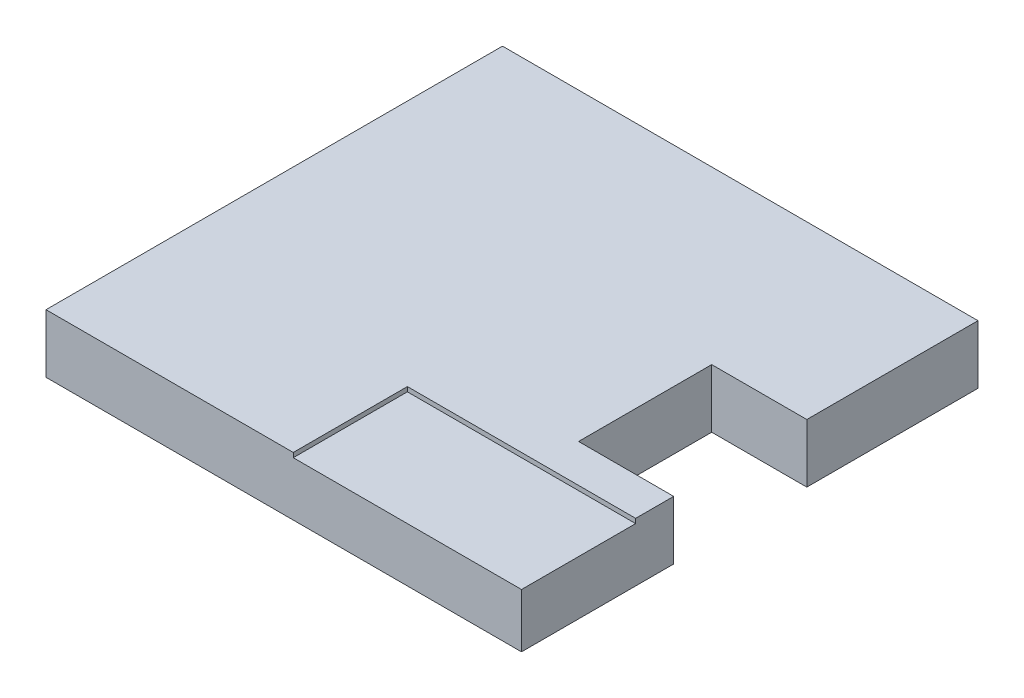
from build123d import *

# Parameters (mm, degrees)
SKETCH1_W           = 6.25
SKETCH1_H           = 6
BOSS_EXTRUDE1_DEPTH = 0.71
BOSS_EXTRUDE2_DEPTH = 0.06
SKETCH3_W           = 1.25
SKETCH3_H           = 1.75
CUT_EXTRUDE1_DEPTH  = 1.71


with BuildPart() as part:
    # Sketch1 → Boss-Extrude1 (new body)
    with BuildSketch(Plane(origin=(0, 0, 0), x_dir=(1, 0, 0), z_dir=(0, 1, 0))):
        Rectangle(SKETCH1_W, SKETCH1_H)
    extrude(amount=BOSS_EXTRUDE1_DEPTH)

    # Sketch2 → Boss-Extrude2 (add)
    with BuildSketch(Plane(origin=(0, 0.71, 0), x_dir=(1, 0, 0), z_dir=(0, 1, 0))):
        Polygon((3.125, 3), (-3.125, 3), (-3.125, -3), (0.125, -3), (0.125, -1.5), (3.125, -1.5), (3.125, -1), (1.875, -1), (1.875, 0.75), (3.125, 0.75), align=None)
    extrude(amount=BOSS_EXTRUDE2_DEPTH)

    # Sketch3 → Cut-Extrude1 (cut, through all)
    with BuildSketch(Plane(origin=(0, 0.71, 0), x_dir=(1, 0, 0), z_dir=(0, 1, 0))):
        with Locations((2.5, -0.125)):
            Rectangle(SKETCH3_W, SKETCH3_H)
    extrude(amount=-CUT_EXTRUDE1_DEPTH, mode=Mode.SUBTRACT)


solid = part.part
